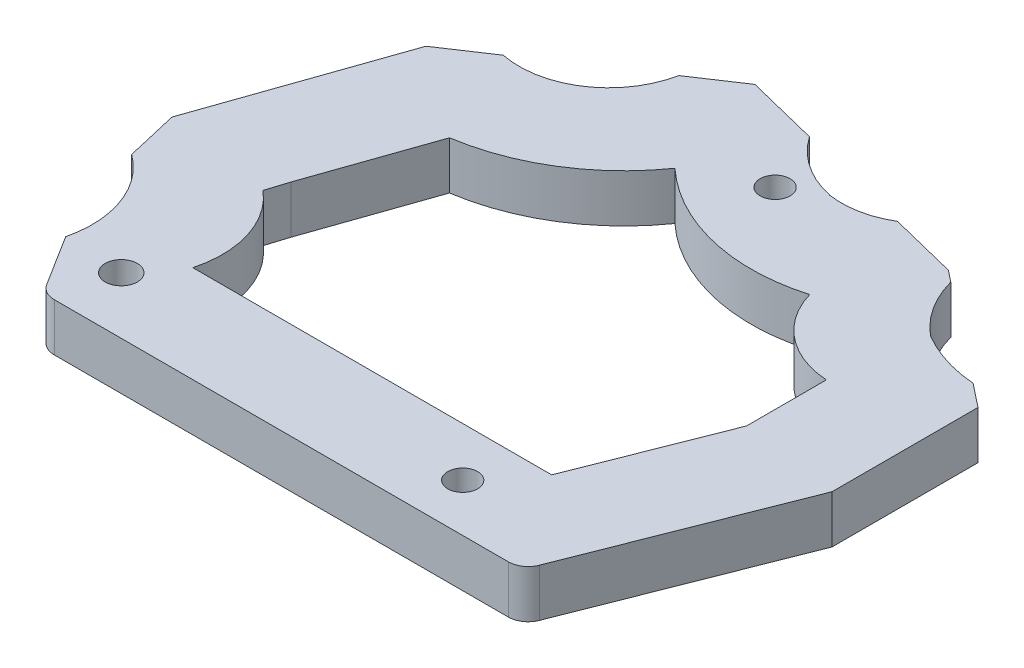
from build123d import *

# Parameters (mm, degrees)
BOSS_EXTRUDE1_DEPTH = 4.8
FILLET1_R           = 2
SKETCH2_R           = 1.5
SKETCH2_R_2         = 1.614746674
CUT_EXTRUDE1_DEPTH  = 10


with BuildPart() as part:
    # Sketch1 → Boss-Extrude1 (new body)
    with BuildSketch(Plane(origin=(0, 0, 0), x_dir=(1, 0, 0), z_dir=(0, 1, 0))):
        with BuildLine():
            Line((-7.626177736, 16.493998363), (-8.85052129, 21.762554574))
            Line((-8.85052129, 21.762554574), (-2.268963588, 40.648610229))
            Line((-2.268963588, 40.648610229), (2.386475485, 43.745687988))
            ThreePointArc((2.386475485, 43.745687988), (9.13418612, 45.073723969), (12.966474819, 50.784139165))
            Line((12.966474819, 50.784139165), (17.54572209, 53.830529559))
            Line((17.54572209, 53.830529559), (24.824248009, 52.021369411))
            ThreePointArc((24.824248009, 52.021369411), (27.493630804, 49.405257048), (30.937059303, 47.951830552))
            ThreePointArc((30.937059303, 47.951830552), (33.863857438, 48.029479081), (36.594025871, 49.08700305))
            Line((36.594025871, 49.08700305), (43.386576908, 47.395479947))
            Line((43.386576908, 47.395479947), (44.534165754, 46.483148945))
            ThreePointArc((44.534165754, 46.483148945), (45.928151501, 43.341073181), (48.215256064, 40.774949823))
            ThreePointArc((48.215256064, 40.774949823), (51.212544898, 39.439353475), (54.434824491, 38.819295269))
            Line((54.434824491, 38.819295269), (56.78893552, 36.959682067))
            Line((56.78893552, 36.959682067), (56.78893552, 22.3328147))
            Line((56.78893552, 22.3328147), (48, 0))
            Line((48, 0), (0, 0))
            Line((0, 0), (-3.788950591, 6.040862349))
            ThreePointArc((-3.788950591, 6.040862349), (-4.118018176, 11.850934579), (-7.626177736, 16.493998363))
        make_face()
        with BuildLine():
            Line((5.26881179, 9.725992339), (41.26881179, 9.725992339))
            Line((41.26881179, 9.725992339), (46.78893552, 23.7527081))
            Line((46.78893552, 23.7527081), (46.78893552, 31.7527081))
            ThreePointArc((46.78893552, 31.7527081), (41.625067619, 33.731492126), (38.544083054, 38.323730364))
            ThreePointArc((38.544083054, 38.323730364), (29.126849272, 38.096934575), (20.817558646, 42.534435867))
            ThreePointArc((20.817558646, 42.534435867), (14.72472781, 36.782412637), (6.864667897, 33.879342365))
            Line((6.864667897, 33.879342365), (2.751194333, 22.075557581))
            Line((2.751194333, 22.075557581), (2.085687611, 19.952561058))
            ThreePointArc((2.085687611, 19.952561058), (5.175485312, 15.305617866), (5.26881179, 9.725992339))
        make_face(mode=Mode.SUBTRACT)
    extrude(amount=BOSS_EXTRUDE1_DEPTH)

    # Fillet1
    fillet1_edges = [part.edges().sort_by_distance(p)[0] for p in [
        (48, 2.4, 0),
        (0, 2.4, 0),
    ]]
    fillet(fillet1_edges, radius=FILLET1_R)

    # Sketch2 → Cut-Extrude1 (cut)
    with BuildSketch(Plane(origin=(0, 4.8, 0), x_dir=(1, 0, 0), z_dir=(0, 1, 0))):
        with Locations((27.493630804, 45.905257048)):
            Circle(SKETCH2_R)
        with Locations((2.124845143, 5.7)):
            Circle(SKETCH2_R_2)
        with Locations((37.26881179, 4.8)):
            Circle(SKETCH2_R)
    extrude(amount=-CUT_EXTRUDE1_DEPTH, mode=Mode.SUBTRACT)


solid = part.part
